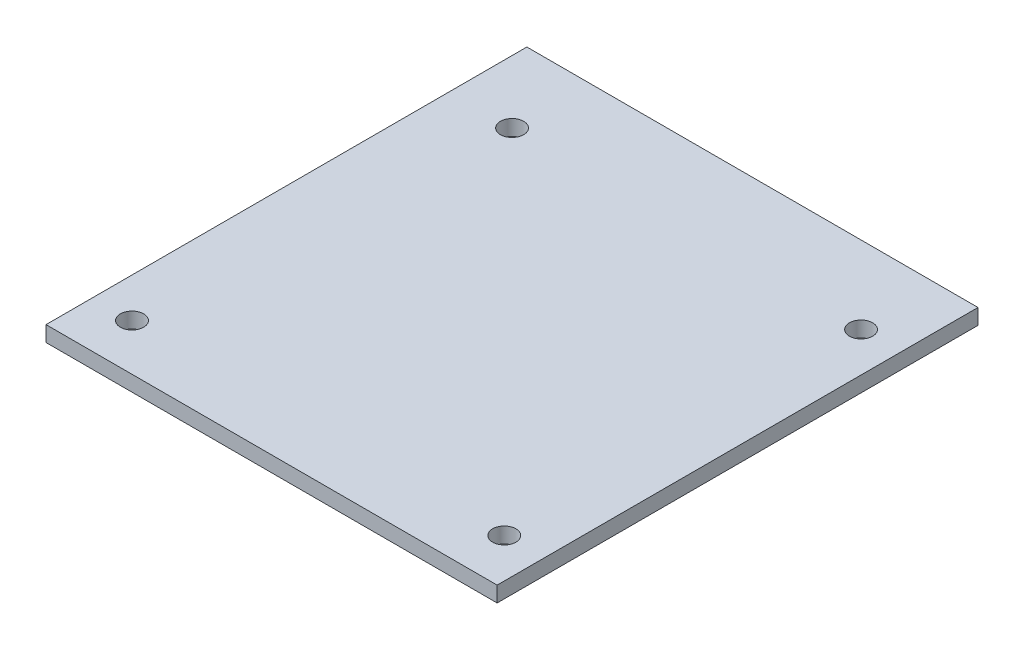
from build123d import *

# Parameters (mm, degrees)
SKETCH1_W           = 58.17
SKETCH1_H           = 62
SKETCH1_R           = 1.5
BOSS_EXTRUDE1_DEPTH = 2


with BuildPart() as part:
    # Sketch1 → Boss-Extrude1 (new body)
    with BuildSketch(Plane(origin=(0, 0, 0), x_dir=(1, 0, 0), z_dir=(0, 1, 0))):
        Rectangle(SKETCH1_W, SKETCH1_H)
        with Locations((24.005, -25)):
            Circle(SKETCH1_R, mode=Mode.SUBTRACT)
        with Locations((-23.995, -25)):
            Circle(SKETCH1_R, mode=Mode.SUBTRACT)
        with Locations((24.005, 21)):
            Circle(SKETCH1_R, mode=Mode.SUBTRACT)
        with Locations((-20.995, 21)):
            Circle(SKETCH1_R, mode=Mode.SUBTRACT)
    extrude(amount=BOSS_EXTRUDE1_DEPTH)


solid = part.part
